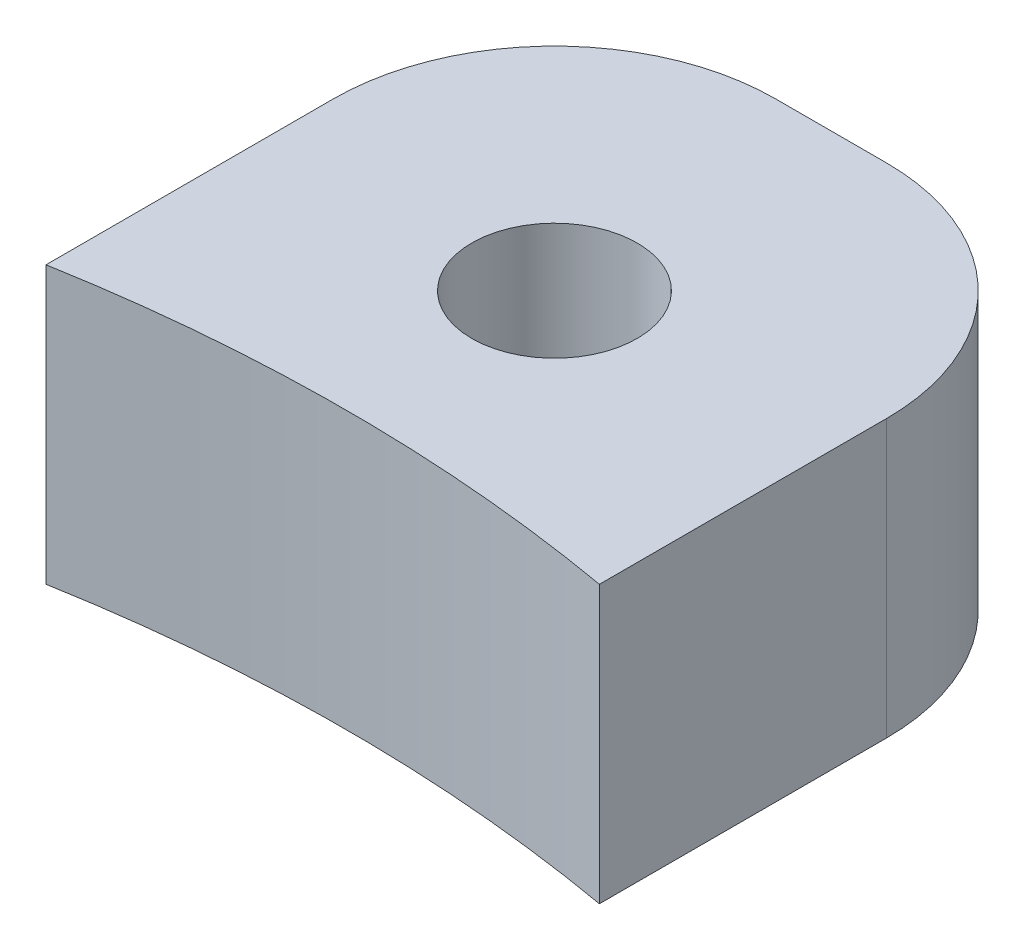
from build123d import *

# Parameters (mm, degrees)
EXTRUDE1_DEPTH            = 6.35
SKETCH2_R                 = 36.5125
CUT_EXTRUDE1_DEPTH        = 6.35
F_6_CLEARANCE_HOLE1_D     = 3.7973
F_6_CLEARANCE_HOLE1_DEPTH = 330.2
F_6_CLEARANCE_HOLE1_TIP   = 1.140824014


with BuildPart() as part:
    # Sketch1 → Extrude1 (new body)
    with BuildSketch(Plane(origin=(0, 0, 0), x_dir=(1, 0, 0), z_dir=(0, 1, 0))):
        with BuildLine():
            Line((-1.27, 22.225), (1.27, 22.225))
            ThreePointArc((1.27, 22.225), (4.862102448, 20.737102448), (6.35, 17.145))
            Line((6.35, 17.145), (6.35, -25.4))
            Line((6.35, -25.4), (-6.35, -25.4))
            Line((-6.35, -25.4), (-6.35, 17.145))
            ThreePointArc((-6.35, 17.145), (-4.862102448, 20.737102448), (-1.27, 22.225))
        make_face()
    extrude(amount=EXTRUDE1_DEPTH)

    # Sketch2 → Cut-Extrude1 (cut)
    with BuildSketch(Plane(origin=(0, 6.35, 0), x_dir=(-1, 0, 0), z_dir=(0, 1, 0))):
        with Locations((0, 25.4)):
            Circle(SKETCH2_R)
    extrude(amount=-CUT_EXTRUDE1_DEPTH, mode=Mode.SUBTRACT)

    # #6 Clearance Hole1
    with Locations(Plane(origin=(0, 6.35, -15.875), x_dir=(0, 0, 1), z_dir=(0, 1, 0))):
        with Locations((0, 0)):
            Hole(F_6_CLEARANCE_HOLE1_D / 2, depth=F_6_CLEARANCE_HOLE1_DEPTH)
            with Locations((0, 0, -(F_6_CLEARANCE_HOLE1_DEPTH + F_6_CLEARANCE_HOLE1_TIP / 2))):  # 118° drill point
                Cone(0, F_6_CLEARANCE_HOLE1_D / 2, F_6_CLEARANCE_HOLE1_TIP, mode=Mode.SUBTRACT)


solid = part.part
